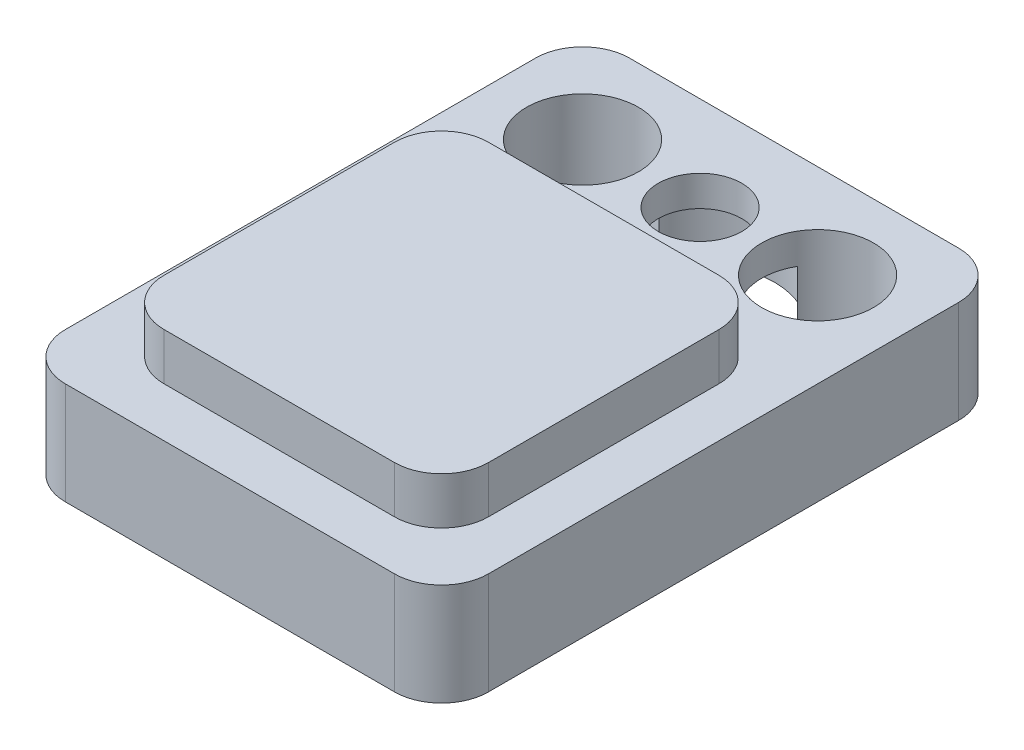
from build123d import *

# Parameters (mm, degrees)
SKETCH1_W                                      = 9
SKETCH1_H                                      = 12
EXTRUDE1_DEPTH                                 = 2.175
SKETCH3_W                                      = 6.9
SKETCH3_H                                      = 6.9
EXTRUDE3_DEPTH                                 = 1
CBORE_FOR_0_SOCKET_HEAD_CAP_SCREW1_D           = 1.778
CBORE_FOR_0_SOCKET_HEAD_CAP_SCREW1_CBORE_D     = 3.175
CBORE_FOR_0_SOCKET_HEAD_CAP_SCREW1_CBORE_DEPTH = 1.524
F_3_32_0_09375_DIAMETER_HOLE1_D                = 2.38125
F_3_32_0_09375_DIAMETER_HOLE1_DEPTH            = 10
F_3_32_0_09375_DIAMETER_HOLE1_TIP              = 0.715399675
FILLET1_R                                      = 1


with BuildPart() as part:
    # Sketch1 → Extrude1 (new body)
    with BuildSketch(Plane(origin=(0, 0, 0), x_dir=(1, 0, 0), z_dir=(0, 1, 0))):
        Rectangle(SKETCH1_W, SKETCH1_H)
    extrude(amount=EXTRUDE1_DEPTH)

    # Sketch3 → Extrude3 (add)
    with BuildSketch(Plane(origin=(0, 2.175, 0), x_dir=(1, 0, 0), z_dir=(0, 1, 0))):
        with Locations((0, -1.5)):
            Rectangle(SKETCH3_W, SKETCH3_H)
    extrude(amount=EXTRUDE3_DEPTH)

    # CBORE for #0 Socket Head Cap Screw1 (through all)
    with Locations(Plane(origin=(0, 0, -4), x_dir=(0, 0, -1), z_dir=(0, -1, 0))):
        with Locations((0, 0)):
            CounterBoreHole(CBORE_FOR_0_SOCKET_HEAD_CAP_SCREW1_D / 2, CBORE_FOR_0_SOCKET_HEAD_CAP_SCREW1_CBORE_D / 2, CBORE_FOR_0_SOCKET_HEAD_CAP_SCREW1_CBORE_DEPTH)

    # 3/32 (0.09375) Diameter Hole1
    with Locations(Plane(origin=(-2.5, 0, -4), x_dir=(0, 0, -1), z_dir=(0, -1, 0))):
        with Locations((0, 0), (0, 5)):
            Hole(F_3_32_0_09375_DIAMETER_HOLE1_D / 2, depth=F_3_32_0_09375_DIAMETER_HOLE1_DEPTH)
            with Locations((0, 0, -(F_3_32_0_09375_DIAMETER_HOLE1_DEPTH + F_3_32_0_09375_DIAMETER_HOLE1_TIP / 2))):  # 118° drill point
                Cone(0, F_3_32_0_09375_DIAMETER_HOLE1_D / 2, F_3_32_0_09375_DIAMETER_HOLE1_TIP, mode=Mode.SUBTRACT)

    # Fillet1
    fillet1_edges = [part.edges().sort_by_distance(p)[0] for p in [
        (-3.45, 2.675, -1.95),
        (-3.45, 2.675, 4.95),
        (3.45, 2.675, 4.95),
        (3.45, 2.675, -1.95),
        (-4.5, 1.0875, -6),
        (4.5, 1.0875, -6),
        (4.5, 1.0875, 6),
        (-4.5, 1.0875, 6),
    ]]
    fillet(fillet1_edges, radius=FILLET1_R)


solid = part.part
